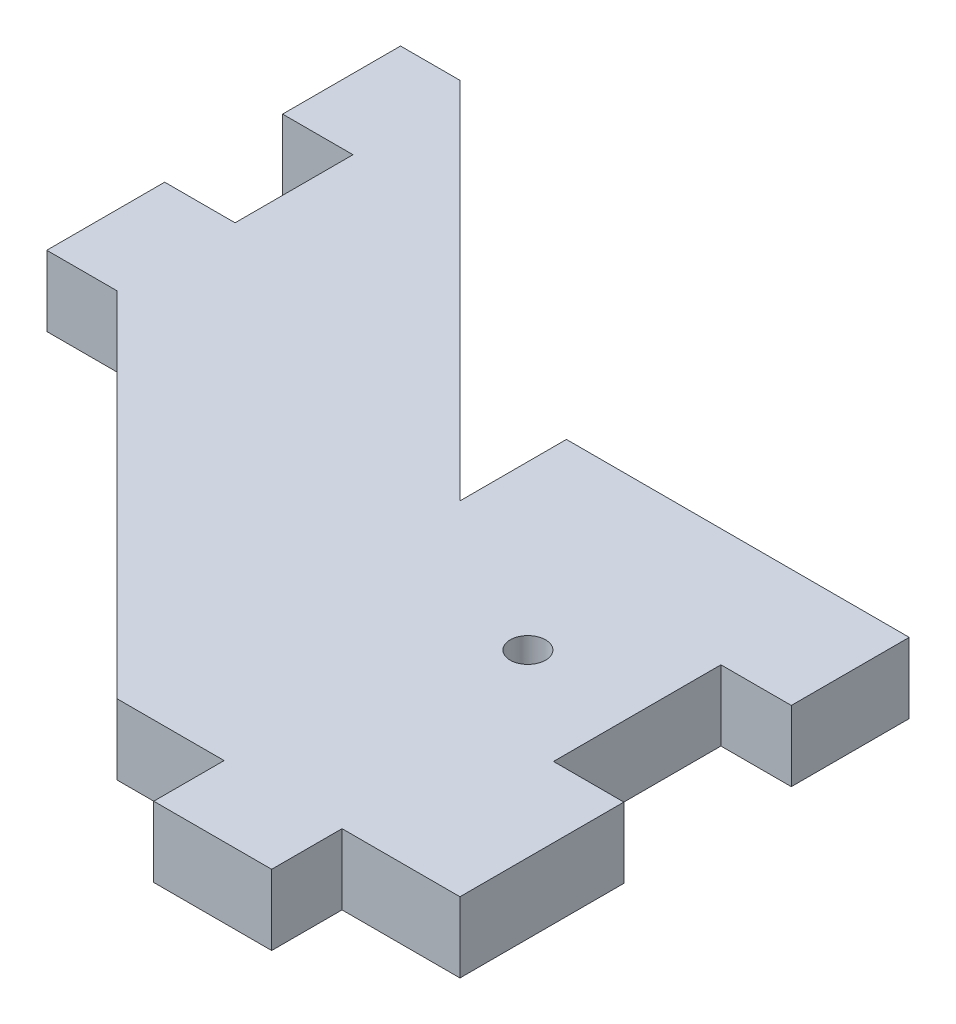
from build123d import *

# Parameters (mm, degrees)
BOSS_EXTRUDE1_DEPTH = 5.969
SKETCH2_R           = 1.5
BOSS_EXTRUDE2_DEPTH = 5.969


with BuildPart() as part:
    # Sketch1 → Boss-Extrude1 (new body)
    with BuildSketch(Plane(origin=(0, 0, 0), x_dir=(1, 0, 0), z_dir=(0, 1, 0))):
        Polygon((0, 0), (-5.969, 0), (-5.969, 10), (0, 10), (0, 20), (-5.969, 20), (-5.969, 30), (-0.928040102, 30), (59.031, -29.959040102), (49.031, -29.959040102), (49.031, -35.928040102), (39.031, -35.928040102), (39.031, -29.959040102), (29.959040102, -29.959040102), align=None)
    extrude(amount=BOSS_EXTRUDE1_DEPTH)

    # Sketch2 → Boss-Extrude2 (add)
    with BuildSketch(Plane(origin=(0, 5.969, 0), x_dir=(1, 0, 0), z_dir=(0, 1, 0))):
        Polygon((59.031, -29.959040102), (29.959040102, -29.959040102), (29.959040102, 8.140959898), (59.031, 8.140959898), (59.031, -1.859040102), (53.062, -1.859040102), (53.062, -16.059040102), (59.031, -16.059040102), align=None)
        with Locations((43.791, -8.959040102)):
            Circle(SKETCH2_R, mode=Mode.SUBTRACT)
    extrude(amount=-BOSS_EXTRUDE2_DEPTH)


solid = part.part
